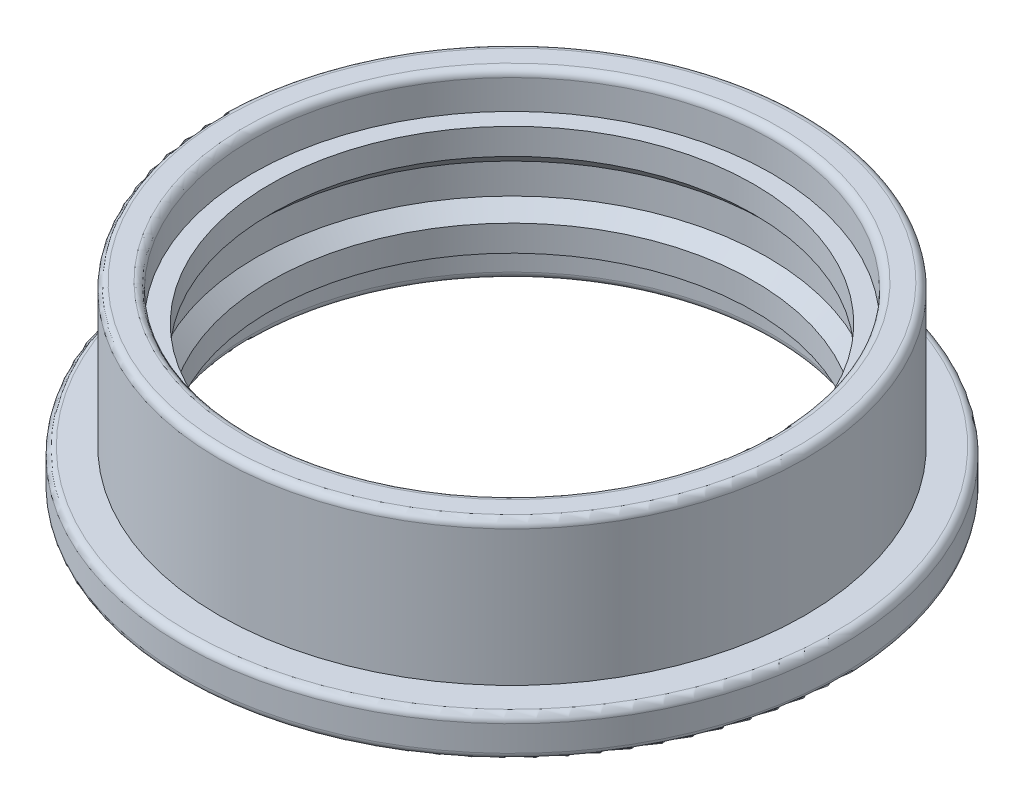
from build123d import *

# Parameters (mm, degrees)
IZIM1_R                     = 9
IZIM1_R_2                   = 6.6
Y_KSEKLIK_EKSTR_ZYON1_DEPTH = 5
IZIM2_R                     = 9
IZIM2_R_2                   = 8
KES_EKSTR_ZYON1_DEPTH       = 3.9
IZIM3_R                     = 7.1
KES_EKSTR_ZYON2_DEPTH       = 1
L_O_ALTMA1_COUNT            = 2
L_O_ALTMA1_PITCH            = 4
RADYUS1_R                   = 0.2


with BuildPart() as part:
    # Çizim1 → Yükseklik-Ekstrüzyon1 (new body)
    with BuildSketch(Plane(origin=(0, 0, 0), x_dir=(1, 0, 0), z_dir=(0, 1, 0))):
        Circle(IZIM1_R)
        Circle(IZIM1_R_2, mode=Mode.SUBTRACT)
    extrude(amount=Y_KSEKLIK_EKSTR_ZYON1_DEPTH)

    # Çizim2 → Kes-Ekstrüzyon1 (cut)
    with BuildSketch(Plane(origin=(0, 5, 0), x_dir=(1, 0, 0), z_dir=(0, 1, 0))):
        Circle(IZIM2_R)
        Circle(IZIM2_R_2, mode=Mode.SUBTRACT)
    extrude(amount=-KES_EKSTR_ZYON1_DEPTH, mode=Mode.SUBTRACT)

    # Çizim3 → Kes-Ekstrüzyon2 (cut)
    with BuildSketch(Plane(origin=(0, 5, 0), x_dir=(1, 0, 0), z_dir=(0, 1, 0))):
        Circle(IZIM3_R)
    kes_ekstr_zyon2 = extrude(amount=-KES_EKSTR_ZYON2_DEPTH, mode=Mode.SUBTRACT)

    # LÇoğaltma1: Kes-Ekstrüzyon2 ×2
    with Locations(*[(0, -i * L_O_ALTMA1_PITCH, 0) for i in range(1, L_O_ALTMA1_COUNT)]):
        add(kes_ekstr_zyon2, mode=Mode.SUBTRACT)

    # Çizim5 → Kes-Döndür1 (revolve, cut)
    with BuildSketch(Plane.XY):
        Polygon((-6.975, 2.914213562), (-6.975, 2.085786438), (-5.889213562, 1), (-5.889213562, 4), align=None)
    revolve(axis=Axis((0, 0, 0), (0, 1, 0)), mode=Mode.SUBTRACT)

    # Radyus1
    radyus1_edges = [part.edges().sort_by_distance(p)[0] for p in [
        (-9, 1.1, 0),
        (-8, 5, 0),
        (-7.1, 5, 0),
        (-9, 0, 0),
        (-7.1, 0, 0),
    ]]
    fillet(radyus1_edges, radius=RADYUS1_R)


solid = part.part
